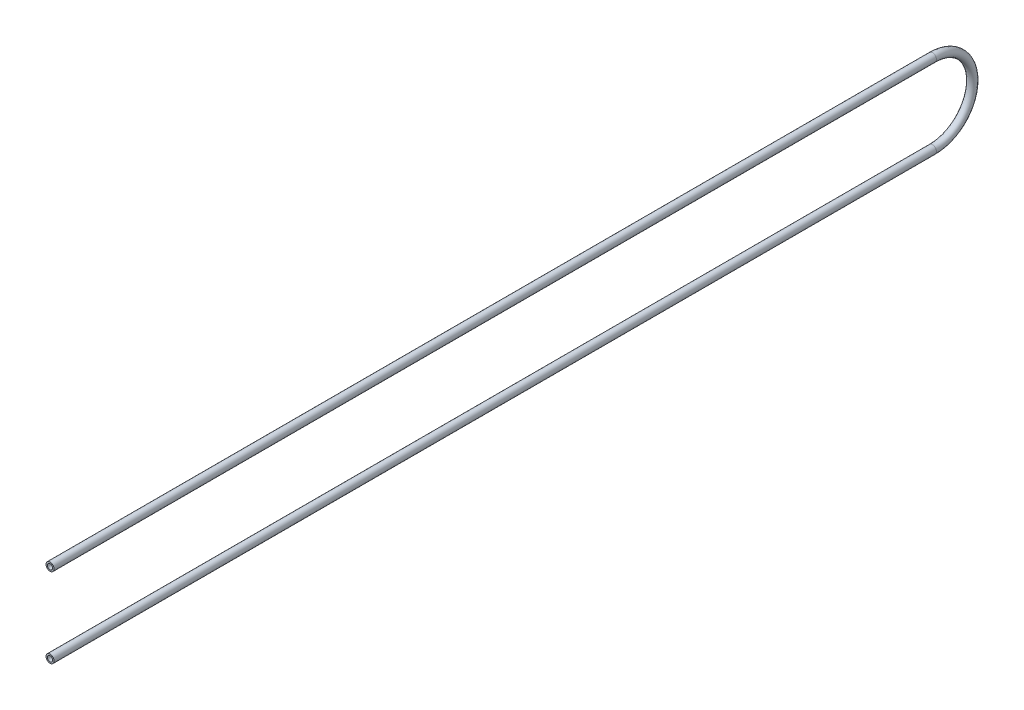
from build123d import *

# Parameters (mm, degrees)
SKETCH2_R   = 10.65
SKETCH2_R_2 = 6.92


with BuildPart() as part:
    # Sweep1: sweep along a path in Sketch1
    with BuildLine(Plane(origin=(0, 0, 0), x_dir=(0, 0, -1), z_dir=(1, 0, 0))) as sweep1_path:
        Line((0, 105), (2325, 105))
        ThreePointArc((2325, 105), (2430, 0), (2325, -105))
        Line((2325, -105), (0, -105))
    # Sketch2 → Sweep1 (sweep)
    with BuildSketch(Plane.XY):
        with Locations((0, 105)):
            Circle(SKETCH2_R)
        with Locations((0, 105)):
            Circle(SKETCH2_R_2, mode=Mode.SUBTRACT)
    sweep(path=sweep1_path.line)


solid = part.part
